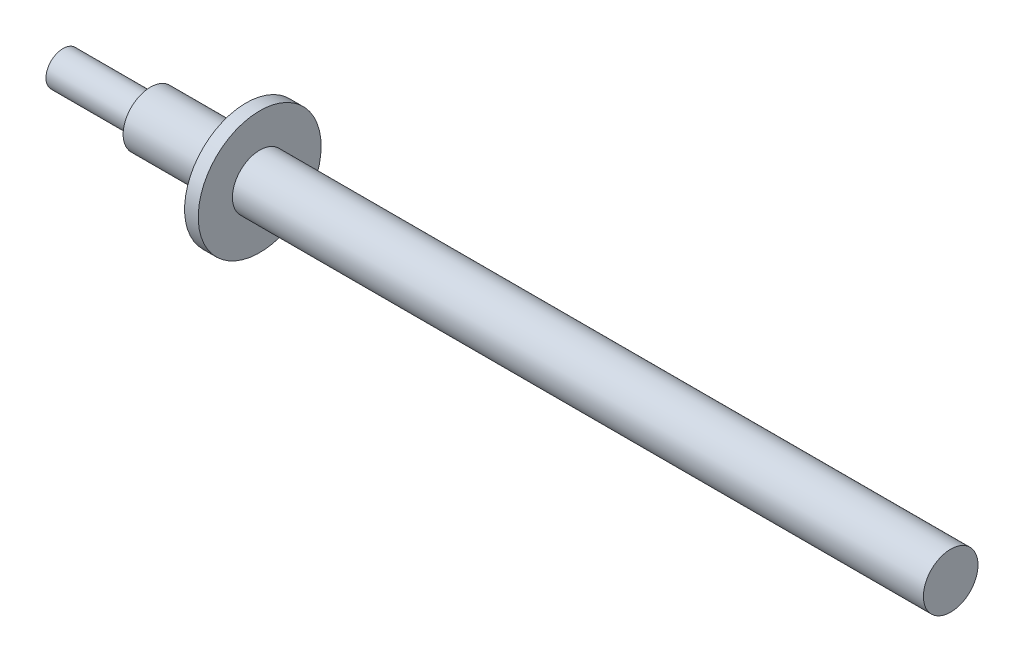
from build123d import *

# Parameters (mm, degrees)
SKETCH1_R           = 2
BOSS_EXTRUDE1_DEPTH = 65
SKETCH2_R           = 4.5
BOSS_EXTRUDE2_DEPTH = 1
SKETCH3_R           = 2
SKETCH3_R_2         = 1.25
CUT_EXTRUDE1_DEPTH  = 6.4


with BuildPart() as part:
    # Sketch1 → Boss-Extrude1 (new body)
    with BuildSketch(Plane(origin=(0, 0, 0), x_dir=(0, 0, -1), z_dir=(1, 0, 0))):
        Circle(SKETCH1_R)
    extrude(amount=BOSS_EXTRUDE1_DEPTH)

    # Sketch2 → Boss-Extrude2 (add)
    with BuildSketch(Plane(origin=(13.4, 0, 0), x_dir=(0, 0, -1), z_dir=(1, 0, 0))):
        Circle(SKETCH2_R)
    extrude(amount=BOSS_EXTRUDE2_DEPTH)

    # Sketch3 → Cut-Extrude1 (cut)
    with BuildSketch(Plane(origin=(0, 0, 0), x_dir=(0, 0, -1), z_dir=(1, 0, 0))):
        Circle(SKETCH3_R)
        Circle(SKETCH3_R_2, mode=Mode.SUBTRACT)
    extrude(amount=CUT_EXTRUDE1_DEPTH, mode=Mode.SUBTRACT)


solid = part.part
